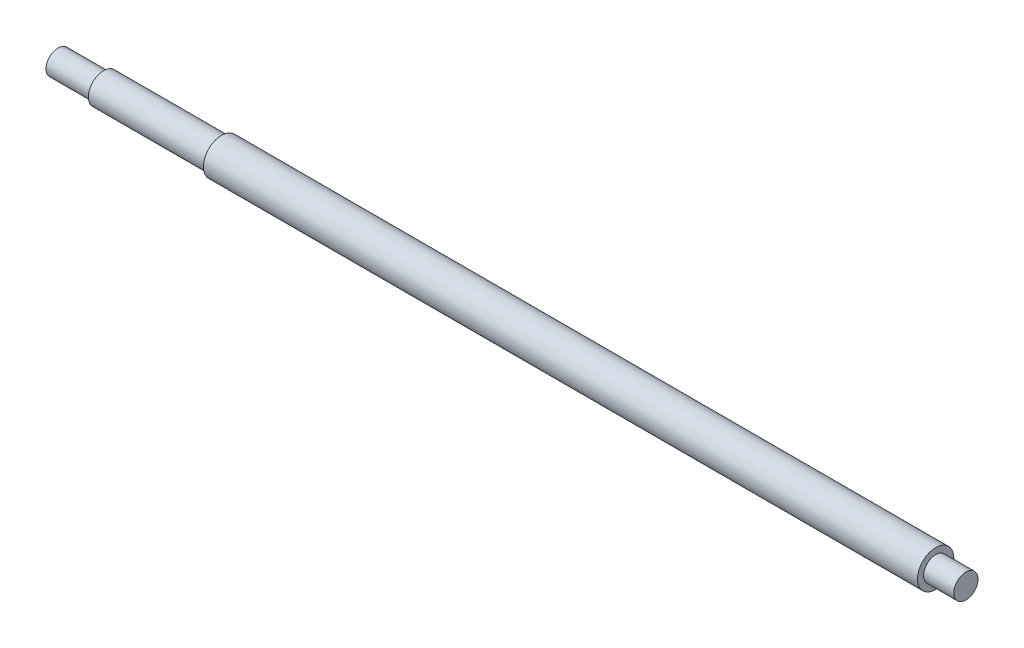
from build123d import *


with BuildPart() as part:
    # 草图1 → 旋转1 (revolve)
    with BuildSketch(Plane.XY):
        Polygon((0, 0), (0, 4), (15, 4), (15, 5), (54, 5), (54, 6), (290, 6), (290, 4), (300, 4), (300, 0), align=None)
    revolve(axis=Axis((0, 0, 0), (1, 0, 0)))


solid = part.part
